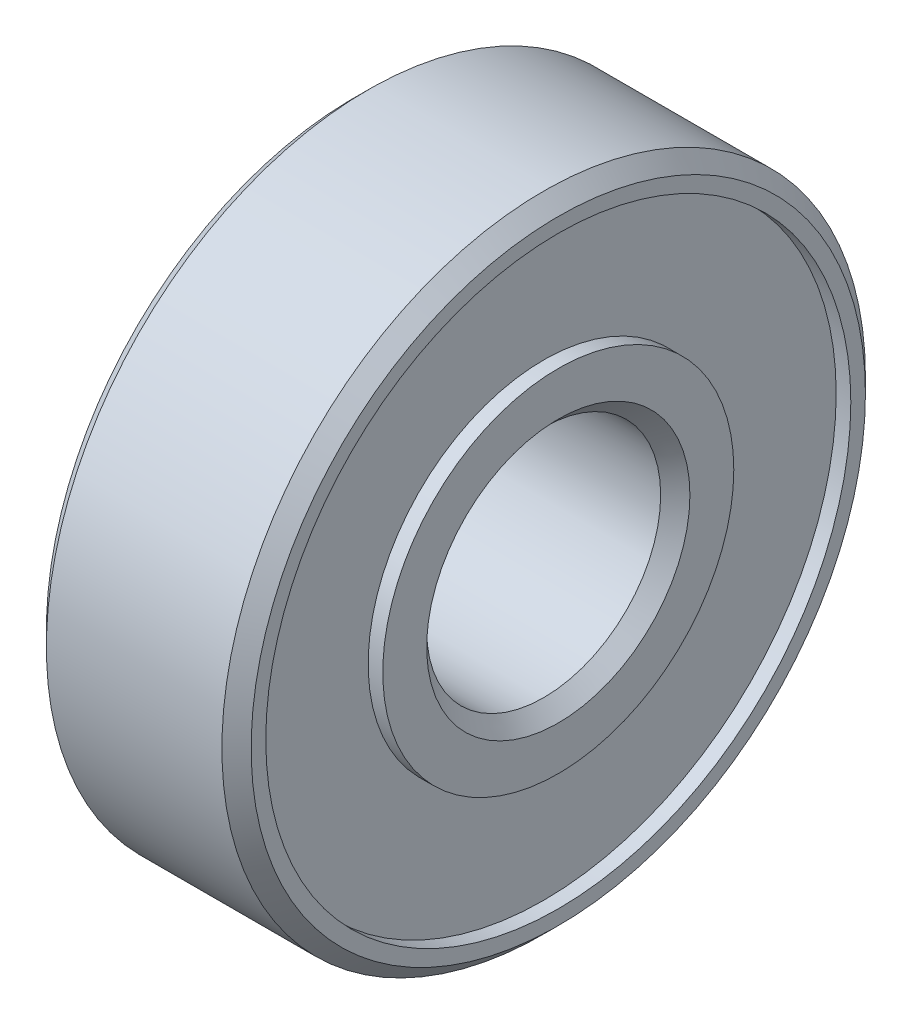
from build123d import *


with BuildPart() as part:
    # Esquisse1 → Révolution1 (revolve)
    with BuildSketch(Plane.XY):
        Polygon((-3, 11), (3, 11), (3.5, 10.5), (3.5, 10), (3, 10), (3, 6), (3.5, 6), (3.5, 4.5), (3, 4), (-3, 4), (-3.5, 4.5), (-3.5, 6), (-3, 6), (-3, 10), (-3.5, 10), (-3.5, 10.5), align=None)
    revolve(axis=Axis((0, 0, 0), (-1, 0, 0)))


solid = part.part
